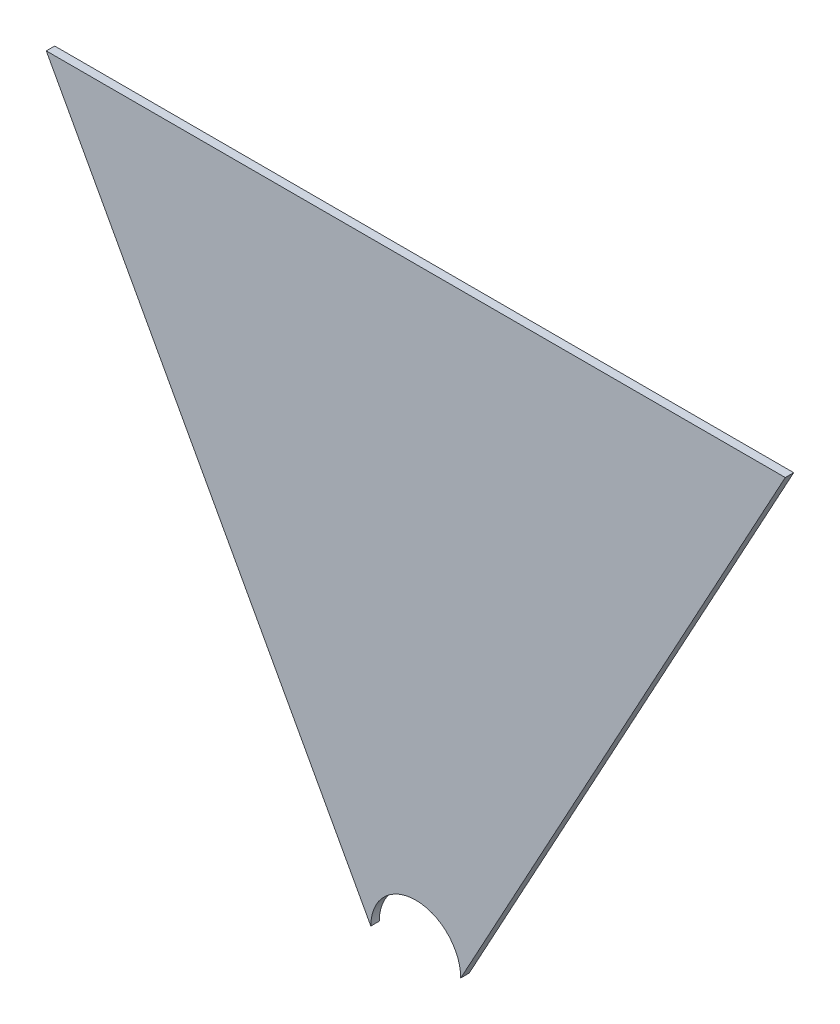
from build123d import *

# Parameters (mm, degrees)
SALIENTE_EXTRUIR1_DEPTH = 3


with BuildPart() as part:
    # Croquis1 → Saliente-Extruir1 (new body)
    with BuildSketch(Plane.XY):
        with BuildLine():
            Line((-131.5, 212), (131.5, 212))
            Line((131.5, 212), (16, 0))
            ThreePointArc((16, 0), (0, 16), (-16, 0))
            Line((-16, 0), (-131.5, 212))
        make_face()
    extrude(amount=SALIENTE_EXTRUIR1_DEPTH)


solid = part.part
